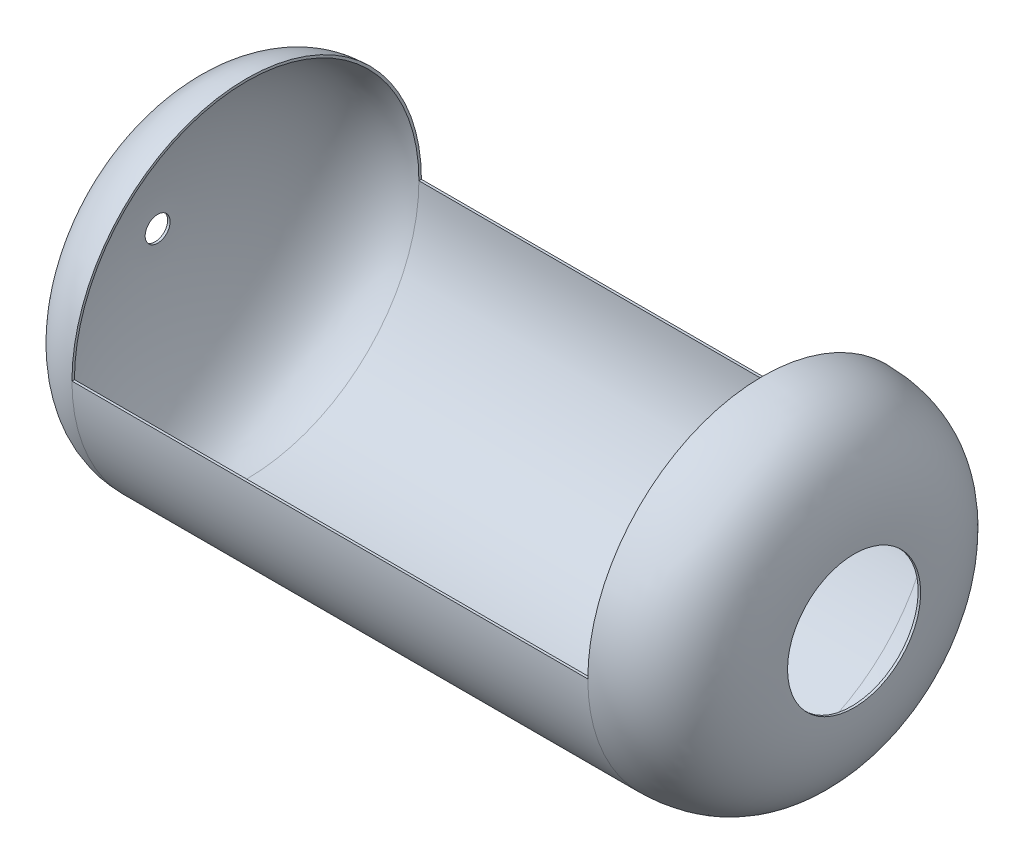
from build123d import *

# Parameters (mm, degrees)
SKETCH4_W          = 958.607886296
SKETCH4_H          = 357.948466727
CUT_EXTRUDE2_DEPTH = 620


with BuildPart() as part:
    # Sketch1 → Revolve1 (revolve)
    with BuildSketch(Plane(origin=(0, 0, 0), x_dir=(1, 0, 0), z_dir=(0, 1, 0))):
        with BuildLine():
            Line((-38.416122965, -102.435963202), (581.583877035, -102.435963202))
            add(Edge.make_bspline(
                [(581.583877035, -102.435963202), (693.455539681, -103.300064727), (691.583877035, -210.80239754), (691.583877035, -232.435963192)],
                knots=[0, 0, 0, 0, 1, 1, 1, 1], degree=3))
            Line((691.583877035, -232.435963192), (688.583877035, -232.435963192))
            add(Edge.make_bspline(
                [(581.572240946, -105.435963202), (582.424150652, -105.442600659), (584.137918536, -105.468851395), (587.484086921, -105.571526796), (591.571096113, -105.792916991), (596.307608869, -106.20262694), (602.409126826, -106.934758126), (609.639419087, -108.18665603), (617.705857071, -110.190510236), (625.186745256, -112.659295822), (634.414245375, -116.523312816), (644.612073728, -122.339029978), (654.913796392, -130.630357057), (663.469285855, -139.982021209), (670.450391217, -150.141502012), (676.016737994, -160.847618745), (680.323342136, -171.829037867), (683.525745861, -182.806951112), (685.782094183, -193.498408861), (687.253383878, -203.618874424), (687.961369137, -211.339785332), (688.299442483, -216.947462036), (688.459593049, -220.834002423), (688.547117141, -224.365875375), (688.582824389, -227.512914091), (688.58674237, -229.777140481), (688.584795317, -231.383827189), (688.583877035, -232.075985649), (688.583877035, -232.435963192)],
                knots=[3.4973e-05, 3.4973e-05, 3.4973e-05, 3.4973e-05, 0.0078472, 0.015659426, 0.03128388, 0.046908334, 0.062532787, 0.093781694, 0.125030601, 0.156279508, 0.187528415, 0.25002623, 0.312524044, 0.375021858, 0.437519672, 0.500017486, 0.562515301, 0.625013115, 0.687510929, 0.750008743, 0.812506557, 0.843755465, 0.875004372, 0.906253279, 0.937502186, 0.968751093, 0.984375546, 1, 1, 1, 1], degree=3))
            Line((581.572240946, -105.435963202), (-38.416122951, -105.435969803))
            add(Edge.make_bspline(
                [(-145.416150087, -297.448719694), (-145.415786094, -297.363118797), (-145.414261278, -297.209117302), (-145.406482156, -296.763589127), (-145.387577621, -296.059017238), (-145.348080967, -294.963719442), (-145.270536885, -293.196191663), (-145.12221169, -290.430217628), (-144.846888777, -286.292241124), (-144.459106758, -281.402026013), (-143.771963774, -273.967299792), (-142.556325425, -263.124157442), (-140.406308296, -248.159348272), (-137.445210779, -231.767940973), (-133.55430361, -214.477141353), (-128.616651259, -196.81526366), (-122.518262583, -179.311948455), (-115.149922932, -162.497881736), (-106.409989847, -146.903194531), (-96.207058742, -133.05233616), (-86.417989624, -123.386032183), (-77.769632288, -117.014146282), (-70.859172034, -112.970513688), (-63.504748075, -109.716446776), (-56.985343251, -107.708604585), (-51.52041341, -106.554160283), (-47.294097057, -105.922162765), (-43.659473987, -105.597170774), (-40.689467236, -105.462466746), (-39.171234927, -105.437583269), (-38.416122951, -105.435969803)],
                knots=[2.115e-05, 2.115e-05, 2.115e-05, 2.115e-05, 0.007833485, 0.015645819, 0.031270489, 0.046895159, 0.062519828, 0.093769167, 0.125018506, 0.156267845, 0.187517184, 0.250015862, 0.312514541, 0.375013219, 0.437511897, 0.500010575, 0.562509253, 0.625007931, 0.687506609, 0.750005287, 0.812503966, 0.843753305, 0.875002644, 0.906251983, 0.937501322, 0.953125991, 0.968750661, 0.98437533, 0.992187665, 1, 1, 1, 1], degree=3))
            Line((-145.416150087, -297.448719694), (-148.416122965, -297.435963202))
            add(Edge.make_bspline(
                [(-38.416122965, -102.435963202), (-139.444928363, -102.64405425), (-148.369931417, -286.57299354), (-148.416122965, -297.435963202)],
                knots=[0, 0, 0, 0, 1, 1, 1, 1], degree=3))
        make_face()
    revolve(axis=Axis((-396.592099756, 0, 312.435963202), (1, 0, 0)))

    # Sketch4 → Cut-Extrude2 (cut)
    with BuildSketch(Plane(origin=(-38.416122965, 0, 0), x_dir=(0, 0, -1), z_dir=(1, 0, 0))):
        with Locations((-258.191988159, 178.974233364)):
            Rectangle(SKETCH4_W, SKETCH4_H)
    extrude(amount=CUT_EXTRUDE2_DEPTH, mode=Mode.SUBTRACT)


solid = part.part
